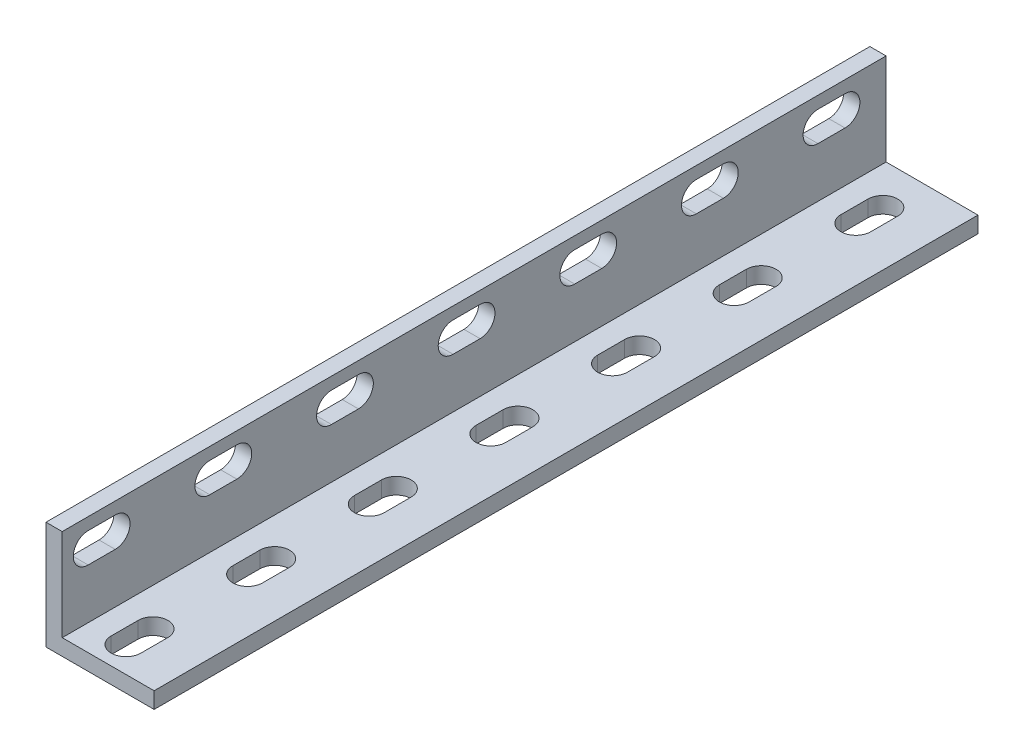
from build123d import *

# Parameters (mm, degrees)
EXTRUDE_THIN1_DEPTH = 152.4
CUT_EXTRUDE1_DEPTH  = 3
CUT_EXTRUDE2_DEPTH  = 3
LPATTERN1_COUNT     = 4
LPATTERN1_PITCH     = 45
LPATTERN2_COUNT     = 4
LPATTERN2_PITCH     = 45


with BuildPart() as part:
    # Sketch1 → Extrude-Thin1 (new body)
    with BuildSketch(Plane.XY):
        Polygon((0, 20), (0, 0), (20, 0), (20, 3), (3, 3), (3, 20), align=None)
    extrude(amount=EXTRUDE_THIN1_DEPTH)

    # Sketch2 → Cut-Extrude1 (cut)
    with BuildSketch(Plane(origin=(0, 3, 0), x_dir=(1, 0, 0), z_dir=(0, 1, 0))):
        with BuildLine():
            Line((7.25, -147.6), (7.25, -142.6))
            ThreePointArc((7.25, -142.6), (10, -139.85), (12.75, -142.6))
            Line((12.75, -142.6), (12.75, -147.6))
            ThreePointArc((12.75, -147.6), (10, -150.35), (7.25, -147.6))
        make_face()
        with BuildLine():
            Line((12.75, -120.1), (12.75, -125.1))
            ThreePointArc((12.75, -125.1), (10, -127.85), (7.25, -125.1))
            Line((7.25, -125.1), (7.25, -120.1))
            ThreePointArc((7.25, -120.1), (10, -117.35), (12.75, -120.1))
        make_face()
        with BuildLine():
            Line((7.25, -102.6), (7.25, -97.6))
            ThreePointArc((7.25, -97.6), (10, -94.85), (12.75, -97.6))
            Line((12.75, -97.6), (12.75, -102.6))
            ThreePointArc((12.75, -102.6), (10, -105.35), (7.25, -102.6))
        make_face()
    cut_extrude1 = extrude(amount=-CUT_EXTRUDE1_DEPTH, mode=Mode.SUBTRACT)

    # Sketch3 → Cut-Extrude2 (cut)
    with BuildSketch(Plane(origin=(3, 0, 0), x_dir=(0, 0, -1), z_dir=(1, 0, 0))):
        with BuildLine():
            Line((-147.6, 17.75), (-142.6, 17.75))
            ThreePointArc((-142.6, 17.75), (-139.85, 15), (-142.6, 12.25))
            Line((-142.6, 12.25), (-147.6, 12.25))
            ThreePointArc((-147.6, 12.25), (-150.35, 15), (-147.6, 17.75))
        make_face()
        with BuildLine():
            Line((-125.1, 17.75), (-120.1, 17.75))
            ThreePointArc((-120.1, 17.75), (-117.35, 15), (-120.1, 12.25))
            Line((-120.1, 12.25), (-125.1, 12.25))
            ThreePointArc((-125.1, 12.25), (-127.85, 15), (-125.1, 17.75))
        make_face()
        with BuildLine():
            Line((-102.6, 17.75), (-97.6, 17.75))
            ThreePointArc((-97.6, 17.75), (-94.85, 15), (-97.6, 12.25))
            Line((-97.6, 12.25), (-102.6, 12.25))
            ThreePointArc((-102.6, 12.25), (-105.35, 15), (-102.6, 17.75))
        make_face()
    cut_extrude2 = extrude(amount=-CUT_EXTRUDE2_DEPTH, mode=Mode.SUBTRACT)

    # LPattern1: Cut-Extrude1 ×4
    with Locations(*[(0, 0, -i * LPATTERN1_PITCH) for i in range(1, LPATTERN1_COUNT)]):
        add(cut_extrude1, mode=Mode.SUBTRACT)

    # LPattern2: Cut-Extrude2 ×4
    with Locations(*[(0, 0, -i * LPATTERN2_PITCH) for i in range(1, LPATTERN2_COUNT)]):
        add(cut_extrude2, mode=Mode.SUBTRACT)


solid = part.part
